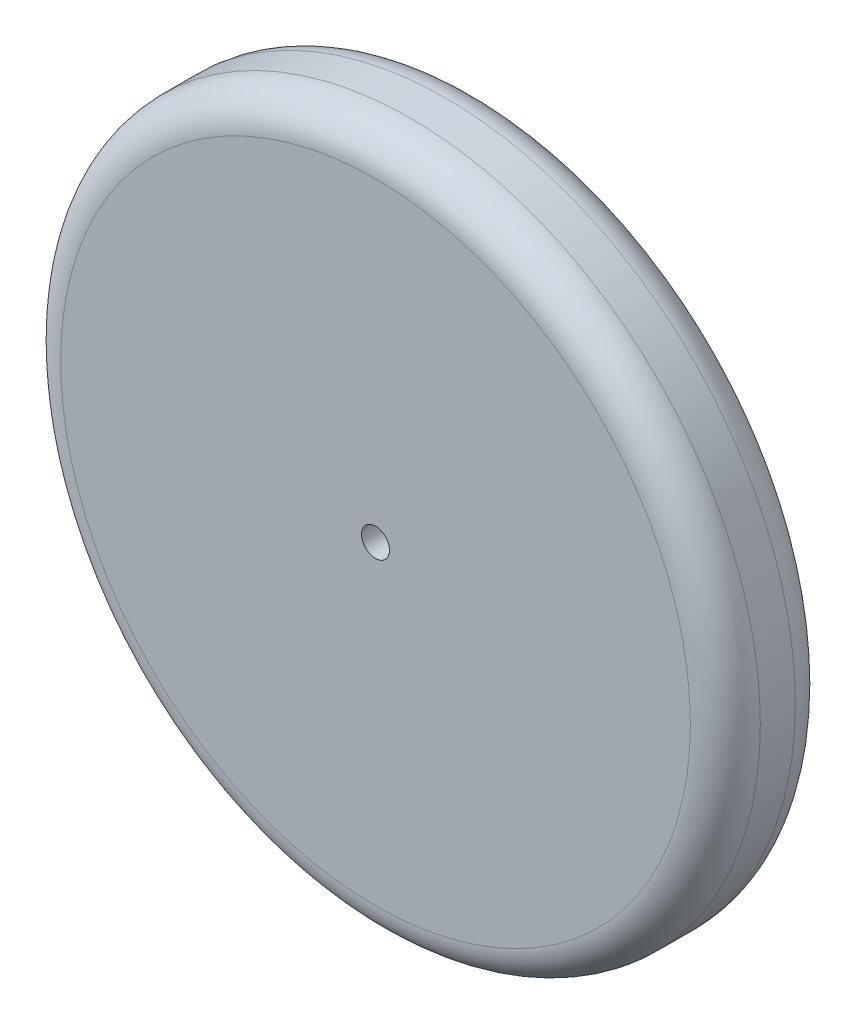
from build123d import *

# Parameters (mm, degrees)
CROQUIS1_R              = 100
CROQUIS1_R_2            = 4
SALIENTE_EXTRUIR1_DEPTH = 30
REDONDEO1_R             = 10
REDONDEO2_R             = 10


with BuildPart() as part:
    # Croquis1 → Saliente-Extruir1 (new body)
    with BuildSketch(Plane.XY):
        Circle(CROQUIS1_R)
        Circle(CROQUIS1_R_2, mode=Mode.SUBTRACT)
    extrude(amount=SALIENTE_EXTRUIR1_DEPTH)

    # Redondeo1
    redondeo1_edges = [part.edges().sort_by_distance(p)[0] for p in [
        (-100, 0, 30),
    ]]
    fillet(redondeo1_edges, radius=REDONDEO1_R)

    # Redondeo2
    redondeo2_edges = [part.edges().sort_by_distance(p)[0] for p in [
        (-100, 0, 0),
    ]]
    fillet(redondeo2_edges, radius=REDONDEO2_R)


solid = part.part
